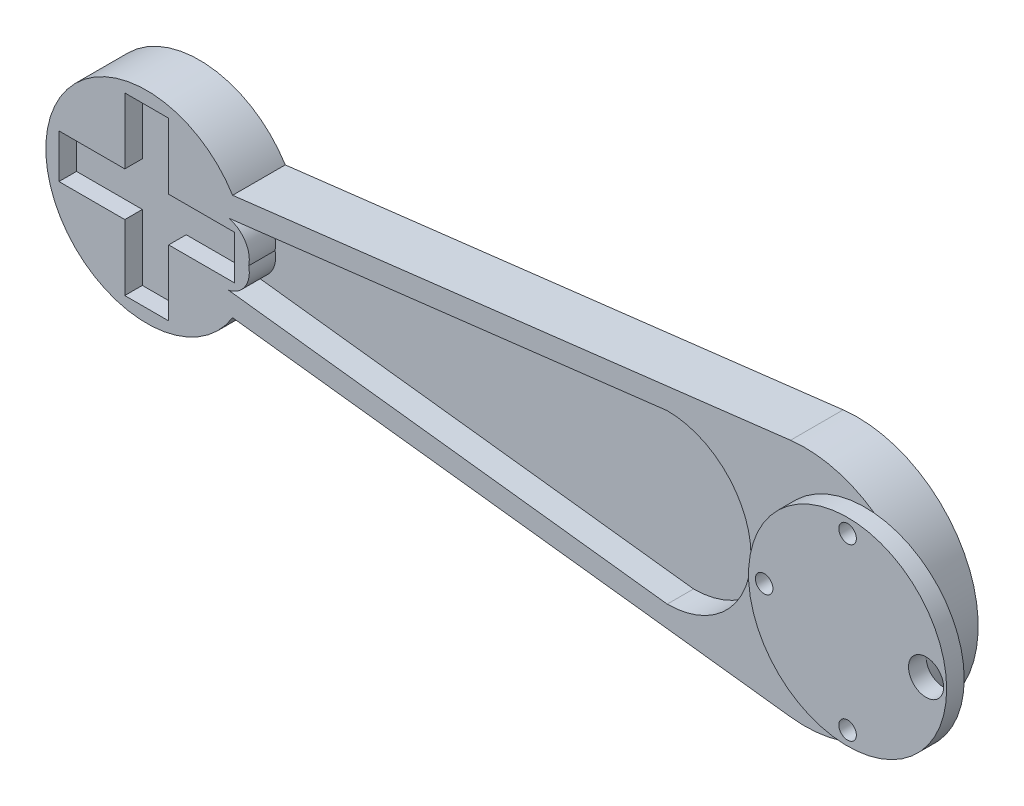
from build123d import *

# Parameters (mm, degrees)
BOSS_EXTRUDE1_DEPTH     = 12
CUT_EXTRUDE1_DEPTH      = 6
SKETCH5_R               = 22.579968686
BOSS_EXTRUDE2_DEPTH     = 4
SKETCH6_R               = 2
CUT_EXTRUDE3_DEPTH      = 16
SKETCH6_3_R             = 2
CUT_EXTRUDE5_DEPTH      = 16
CUT_EXTRUDE8_DEPTH      = 167.374625231
CUT_EXTRUDE8_DEPTH_BACK = 167.374625231
SKETCH8_R               = 4
CUT_EXTRUDE9_DEPTH      = 4


with BuildPart() as part:
    # Sketch1 → Boss-Extrude1 (new body)
    with BuildSketch(Plane.XY):
        with BuildLine():
            Line((6.425984457, 27.304915127), (-120.730550627, 12.077737738))
            ThreePointArc((-120.730550627, 12.077737738), (-163.304212807, 0), (-120.730550627, -12.077737738))
            Line((-120.730550627, -12.077737738), (6.425984457, -27.304915127))
            ThreePointArc((6.425984457, -27.304915127), (37.195787193, 0), (6.425984457, 27.304915127))
        make_face()
    extrude(amount=BOSS_EXTRUDE1_DEPTH)

    # Sketch3 → Cut-Extrude1 (cut)
    with BuildSketch(Plane.XY.offset(12)):
        with BuildLine():
            Line((-121.670322635, 7.122377923), (-21.678965717, 19.096486278))
            ThreePointArc((-21.678965717, 19.096486278), (-2.5738344, 0), (-21.678965717, -19.096486278))
            Line((-21.678965717, -19.096486278), (-121.670322635, -7.122377923))
            ThreePointArc((-121.670322635, -7.122377923), (-117.889637025, -4.516196787), (-117.059136947, 0))
            ThreePointArc((-117.059136947, 0), (-117.889637025, 4.516196787), (-121.670322635, 7.122377923))
        make_face()
    extrude(amount=-CUT_EXTRUDE1_DEPTH, mode=Mode.SUBTRACT)

    # Sketch5 → Boss-Extrude2 (add)
    with BuildSketch(Plane.XY.offset(12)):
        with Locations((23.433246409, 0)):
            Circle(SKETCH5_R)
    extrude(amount=BOSS_EXTRUDE2_DEPTH)

    # Sketch6 → Cut-Extrude3 (cut)
    with BuildSketch(Plane.XY.offset(16)):
        with Locations((4.416689948, 0)):
            Circle(SKETCH6_R)
    extrude(amount=-CUT_EXTRUDE3_DEPTH, mode=Mode.SUBTRACT)

    # Sketch6_3 → Cut-Extrude5 (cut)
    with BuildSketch(Plane.XY.offset(16)):
        with Locations((23.433246409, -19.392257926)):
            Circle(SKETCH6_3_R)
        with Locations((42.449802871, 0)):
            Circle(SKETCH6_3_R)
        with Locations((23.433246409, 19.392257926)):
            Circle(SKETCH6_3_R)
    extrude(amount=-CUT_EXTRUDE5_DEPTH, mode=Mode.SUBTRACT)

    # Sketch8 → Cut-Extrude8 (cut, two sides: drawn at the far end of the back side and taken through both)
    with BuildSketch(Plane.XY.offset(16).offset(-CUT_EXTRUDE8_DEPTH_BACK)):
        with Locations((41.318582697, 0)):
            Circle(SKETCH8_R)
    extrude(amount=CUT_EXTRUDE8_DEPTH + CUT_EXTRUDE8_DEPTH_BACK, mode=Mode.SUBTRACT)

    # Sketch10 → Cut-Extrude9 (cut)
    with BuildSketch(Plane.XY.offset(12)):
        Polygon((-145.304212807, -5), (-145.304212807, -20), (-140.304212807, -20), (-135.304212807, -20), (-135.304212807, -5), (-120.304212807, -5), (-120.304212807, 5), (-135.304212807, 5), (-135.304212807, 20), (-140.304212807, 20), (-145.304212807, 20), (-145.304212807, 5), (-160.304212807, 5), (-160.304212807, -5), align=None)
    extrude(amount=-CUT_EXTRUDE9_DEPTH, mode=Mode.SUBTRACT)


solid = part.part
